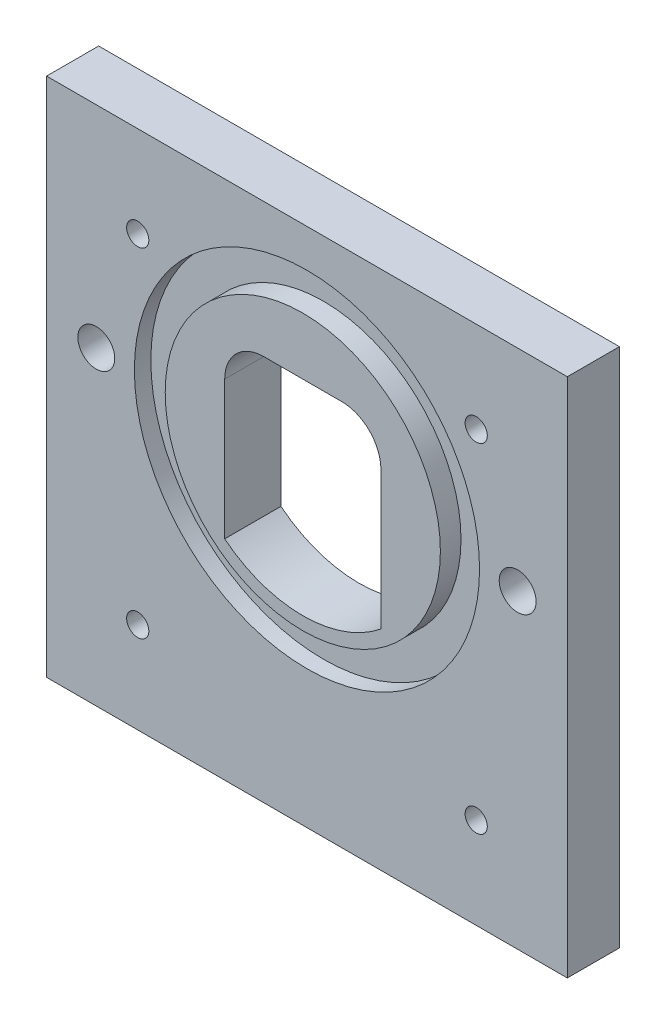
from build123d import *

# Parameters (mm, degrees)
SKETCH1_W                                       = 63.5
SKETCH1_H                                       = 63.5
BOSS_EXTRUDE1_DEPTH                             = 6.35
F_6_32_TAPPED_HOLE1_D                           = 2.7051
SKETCH4_R                                       = 21.0439
SKETCH4_R_2                                     = 16.7767
CUT_EXTRUDE1_DEPTH                              = 2.0066
SKETCH5_R                                       = 16.7767
BOSS_EXTRUDE2_DEPTH                             = 0.508
CSK_FOR_M4_FLAT_HEAD_MACHINE_SCREW1_D           = 4.5
CSK_FOR_M4_FLAT_HEAD_MACHINE_SCREW1_CSINK_D     = 9.4
CSK_FOR_M4_FLAT_HEAD_MACHINE_SCREW1_CSINK_ANGLE = 90
CUT_EXTRUDE2_DEPTH                              = 7.858


with BuildPart() as part:
    # Sketch1 → Boss-Extrude1 (new body)
    with BuildSketch(Plane.XY):
        Rectangle(SKETCH1_W, SKETCH1_H)
    extrude(amount=BOSS_EXTRUDE1_DEPTH)

    # #6-32 Tapped Hole1 (through all)
    with Locations(Plane(origin=(0, 0, 0), x_dir=(-1, 0, 0), z_dir=(0, 0, -1))):
        with Locations((20.6375, -20.6375), (-20.6375, -20.6375), (-20.6375, 20.6375), (20.6375, 20.6375)):
            Hole(F_6_32_TAPPED_HOLE1_D / 2)

    # Sketch4 → Cut-Extrude1 (cut)
    with BuildSketch(Plane.XY.offset(6.35)):
        with Locations((0, 6.076865153)):
            Circle(SKETCH4_R)
        with Locations((0, 6.076865153)):
            Circle(SKETCH4_R_2, mode=Mode.SUBTRACT)
    extrude(amount=-CUT_EXTRUDE1_DEPTH, mode=Mode.SUBTRACT)

    # Sketch5 → Boss-Extrude2 (add)
    with BuildSketch(Plane.XY.offset(6.35)):
        with Locations((0, 6.076865153)):
            Circle(SKETCH5_R)
    extrude(amount=BOSS_EXTRUDE2_DEPTH)

    # CSK for M4 Flat Head Machine Screw1 (through all)
    with Locations(Plane(origin=(0, 0, 0), x_dir=(-1, 0, 0), z_dir=(0, 0, -1))):
        with Locations((-25.691176831, 6.076865153), (25.691176831, 6.076865153)):
            CounterSinkHole(CSK_FOR_M4_FLAT_HEAD_MACHINE_SCREW1_D / 2, CSK_FOR_M4_FLAT_HEAD_MACHINE_SCREW1_CSINK_D / 2, counter_sink_angle=CSK_FOR_M4_FLAT_HEAD_MACHINE_SCREW1_CSINK_ANGLE)

    # Sketch9 → Cut-Extrude2 (cut, through all)
    with BuildSketch(Plane(origin=(0, 0, 0), x_dir=(-1, 0, 0), z_dir=(0, 0, -1))):
        with BuildLine():
            Line((9.525, 11.1125), (9.525, -5.754710044))
            ThreePointArc((9.525, -5.754710044), (0, -9.112334847), (-9.525, -5.754710044))
            Line((-9.525, -5.754710044), (-9.525, 11.1125))
            ThreePointArc((-9.525, 11.1125), (-8.130096045, 14.480096045), (-4.7625, 15.875))
            Line((-4.7625, 15.875), (4.7625, 15.875))
            ThreePointArc((4.7625, 15.875), (8.130096045, 14.480096045), (9.525, 11.1125))
        make_face()
    extrude(amount=-CUT_EXTRUDE2_DEPTH, mode=Mode.SUBTRACT)


solid = part.part
